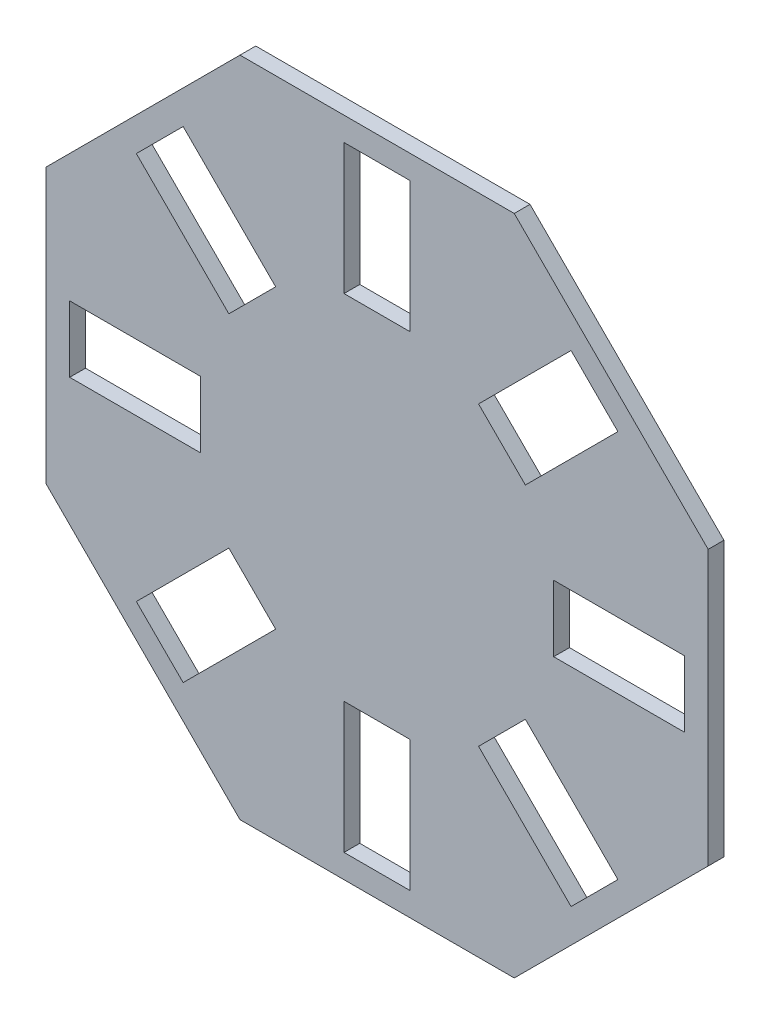
from build123d import *

# Parameters (mm, degrees)
SKETCH1_W           = 41.5
SKETCH1_H           = 21
SKETCH1_W_2         = 21
SKETCH1_H_2         = 41.5
BOSS_EXTRUDE1_DEPTH = 5


with BuildPart() as part:
    # Sketch1 → Boss-Extrude1 (new body)
    with BuildSketch(Plane.XY):
        Polygon((105, 43.492424049), (43.492424049, 105), (-43.492424049, 105), (-105, 43.492424049), (-105, -43.492424049), (-43.492424049, -105), (43.492424049, -105), (105, -43.492424049), align=None)
        Polygon((47.022600949, -32.173358544), (76.367532368, -61.518289963), (61.518289963, -76.367532368), (32.173358544, -47.022600949), align=None, mode=Mode.SUBTRACT)
        with Locations((76.75, 0)):
            Rectangle(SKETCH1_W, SKETCH1_H, mode=Mode.SUBTRACT)
        with Locations((0, -76.75)):
            Rectangle(SKETCH1_W_2, SKETCH1_H_2, mode=Mode.SUBTRACT)
        Polygon((-32.173358544, -47.022600949), (-61.518289963, -76.367532368), (-76.367532368, -61.518289963), (-47.022600949, -32.173358544), align=None, mode=Mode.SUBTRACT)
        with Locations((-76.75, 0)):
            Rectangle(SKETCH1_W, SKETCH1_H, mode=Mode.SUBTRACT)
        Polygon((-47.022600949, 32.173358544), (-76.367532368, 61.518289963), (-61.518289963, 76.367532368), (-32.173358544, 47.022600949), align=None, mode=Mode.SUBTRACT)
        with Locations((0, 76.75)):
            Rectangle(SKETCH1_W_2, SKETCH1_H_2, mode=Mode.SUBTRACT)
        Polygon((32.173358544, 47.022600949), (61.518289963, 76.367532368), (76.367532368, 61.518289963), (47.022600949, 32.173358544), align=None, mode=Mode.SUBTRACT)
    extrude(amount=BOSS_EXTRUDE1_DEPTH)


solid = part.part
